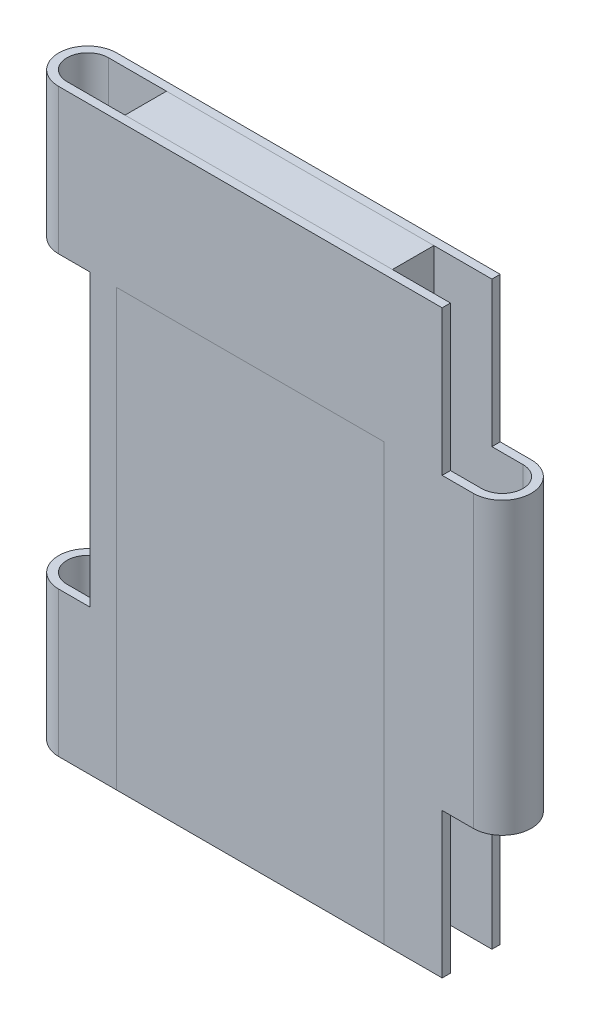
from build123d import *

# Parameters (mm, degrees)
BOSS_EXTRUDE1_DEPTH = 70
SKETCH2_W           = 7.5
SKETCH2_H           = 17.5
SKETCH2_H_2         = 35
CUT_EXTRUDE1_DEPTH  = 7
SKETCH3_W           = 32.25
SKETCH3_H           = 7
BOSS_EXTRUDE2_DEPTH = 70


with BuildPart() as part:
    # Sketch1 → Boss-Extrude1 (new body)
    with BuildSketch(Plane(origin=(0, 0, 0), x_dir=(1, 0, 0), z_dir=(0, 1, 0))):
        with BuildLine():
            Line((-25, 3.5), (25, 3.5))
            ThreePointArc((25, 3.5), (28.5, 0), (25, -3.5))
            Line((25, -3.5), (-25, -3.5))
            ThreePointArc((-25, -3.5), (-28.5, 0), (-25, 3.5))
        make_face()
        with BuildLine():
            Line((-25, 2.5), (25, 2.5))
            ThreePointArc((25, 2.5), (27.5, 0), (25, -2.5))
            Line((25, -2.5), (-25, -2.5))
            ThreePointArc((-25, -2.5), (-27.5, 0), (-25, 2.5))
        make_face(mode=Mode.SUBTRACT)
    extrude(amount=BOSS_EXTRUDE1_DEPTH)

    # Sketch2 → Cut-Extrude1 (cut)
    with BuildSketch(Plane.XY.offset(3.5)):
        with Locations((25, 61.25)):
            Rectangle(SKETCH2_W, SKETCH2_H)
        with Locations((-25, 35)):
            Rectangle(SKETCH2_W, SKETCH2_H_2)
        with Locations((25, 8.75)):
            Rectangle(SKETCH2_W, SKETCH2_H)
    extrude(amount=-CUT_EXTRUDE1_DEPTH, mode=Mode.SUBTRACT)


with BuildPart() as body_2:
    # Sketch3 → Boss-Extrude2 (new body)
    with BuildSketch(Plane(origin=(0, 70, 0), x_dir=(1, 0, 0), z_dir=(0, 1, 0))):
        with Locations((-1.875, 0)):
            Rectangle(SKETCH3_W, SKETCH3_H)
    extrude(amount=-BOSS_EXTRUDE2_DEPTH)


solid = Compound([part.part, body_2.part])
